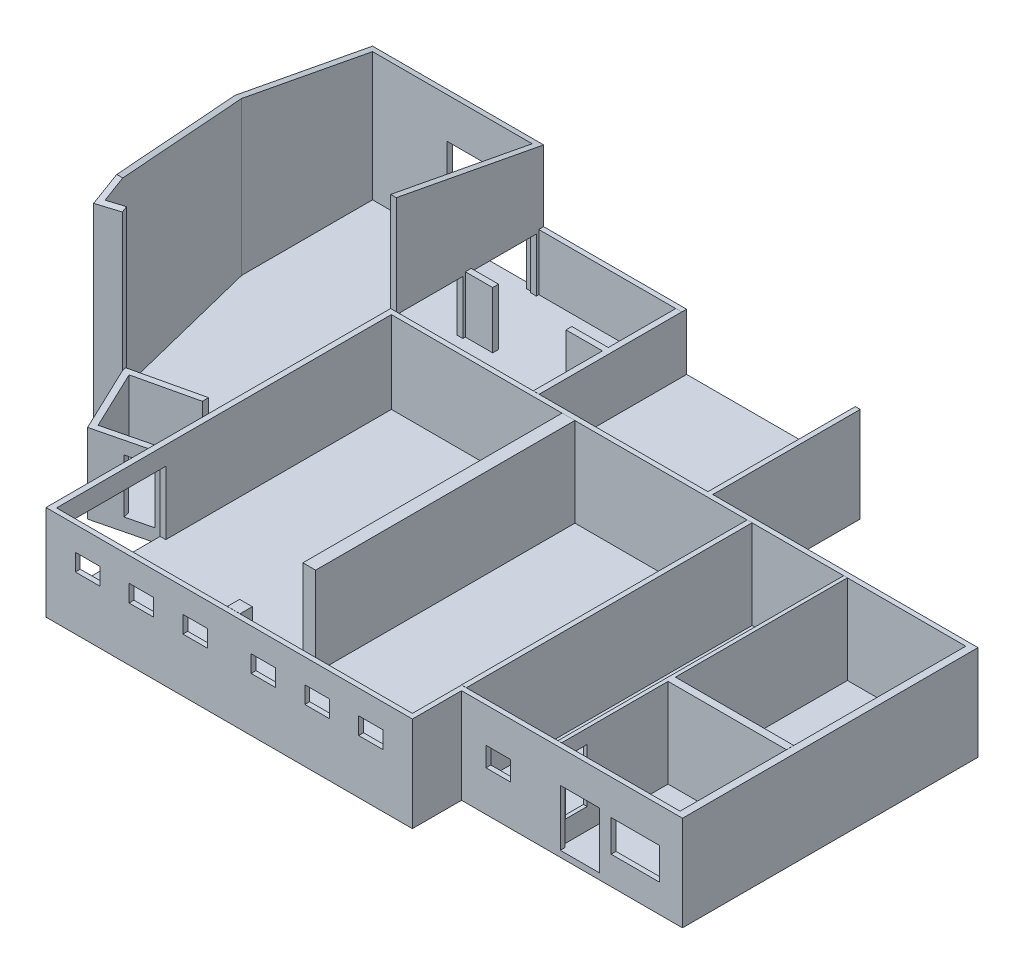
from build123d import *

# Parameters (mm, degrees)
AUFSATZ_LINEAR_AUSTRAGEN4_DEPTH      = 250
SKIZZE5_W                            = 12750
SKIZZE5_H                            = 5830
AUFSATZ_LINEAR_AUSTRAGEN5_DEPTH      = 3635
SKIZZE6_W                            = 200
SKIZZE6_H                            = 11690
SKIZZE6_W_2                          = 520
SKIZZE6_H_2                          = 10610
SKIZZE6_H_3                          = 500
SKIZZE6_W_3                          = 1120
SKIZZE6_H_4                          = 240
AUFSATZ_LINEAR_AUSTRAGEN6_DEPTH      = 3640
SCHNITT_LINEAR_AUSTRAGEN1_REACH      = 30348.456
SKIZZE7_W                            = 1980
SKIZZE7_H                            = 1300
SKIZZE7_W_2                          = 1600
SKIZZE7_H_2                          = 2300
SKIZZE7_W_3                          = 1000
SKIZZE7_H_3                          = 800
SCHNITT_LINEAR_AUSTRAGEN2_REACH      = 27879.968
SKIZZE8_W                            = 890
SKIZZE8_H                            = 2200
SCHNITT_LINEAR_AUSTRAGEN3_REACH      = 31589.813
SKIZZE9_W                            = 3870
SKIZZE9_H                            = 2600
SKIZZE9_W_2                          = 2565
SKIZZE9_H_2                          = 2200
AUFSATZ_LINEAR_AUSTRAGEN7_DEPTH      = 3000
SKIZZE11_W                           = 6990
SKIZZE11_H                           = 13700
AUFSATZ_LINEAR_AUSTRAGEN8_DEPTH      = 275
SKIZZE12_W                           = 12750
SKIZZE12_H                           = 5830
AUFSATZ_LINEAR_AUSTRAGEN9_DEPTH      = 1325
AUFSATZ_LINEAR_AUSTRAGEN10_REACH     = 31462.736
SCHNITT_LINEAR_AUSTRAGEN4_DEPTH      = 3090
AUFSATZ_LINEAR_AUSTRAGEN12_DEPTH     = 8000
AUFSATZ_LINEAR_AUSTRAGEN13_DEPTH     = 1575
SCHNITT_LINEAR_AUSTRAGEN8_DEPTH      = 37827.06409607
SCHNITT_LINEAR_AUSTRAGEN8_DEPTH_BACK = 37827.06409607
AUFSATZ_LINEAR_AUSTRAGEN14_REACH     = 31776.265
SKIZZE21_W                           = 230
SKIZZE21_H                           = 6030
SCHNITT_LINEAR_AUSTRAGEN9_DEPTH      = 1200
SCHNITT_LINEAR_AUSTRAGEN10_DEPTH     = 1050
SKIZZE24_W                           = 1040
SKIZZE24_H                           = 2200
SCHNITT_LINEAR_AUSTRAGEN11_DEPTH     = 300
SCHNITT_LINEAR_AUSTRAGEN12_REACH     = 32636.812
SKIZZE25_W                           = 1000
SKIZZE25_H                           = 700
SCHNITT_LINEAR_AUSTRAGEN13_REACH     = 32513.828
SKIZZE26_W                           = 6900
SKIZZE26_H                           = 3817.744695197
SCHNITT_LINEAR_AUSTRAGEN14_REACH     = 32489.323
SKIZZE27_W                           = 3250
SKIZZE27_H                           = 3600


with BuildPart() as part:
    # Skizze1 → Aufsatz-Linear austragen4 (new body)
    with BuildSketch(Plane(origin=(0, 0, 0), x_dir=(1, 0, 0), z_dir=(0, 1, 0))):
        Polygon((14990, -18120), (14990, -20130), (0, -20130), (0, 0), (13180, 0), (13180, -6030), (24030, -6030), (24030, -18120), align=None)
    extrude(amount=AUFSATZ_LINEAR_AUSTRAGEN4_DEPTH)

    # Skizze5 → Aufsatz-Linear austragen5 (add)
    with BuildSketch(Plane(origin=(0, 250, 0), x_dir=(1, 0, 0), z_dir=(0, 1, 0))):
        Polygon((0, -20130), (14990, -20130), (14990, -18120), (24030, -18120), (24030, -6030), (13180, -6030), (13180, 0), (0, 0), align=None)
        Polygon((23730, -6230), (23730, -17920), (14790, -17920), (14790, -19930), (230, -19930), (230, -6230), align=None, mode=Mode.SUBTRACT)
        with Locations((6605, -3115)):
            Rectangle(SKIZZE5_W, SKIZZE5_H, mode=Mode.SUBTRACT)
    extrude(amount=AUFSATZ_LINEAR_AUSTRAGEN5_DEPTH)

    # Skizze6 → Aufsatz-Linear austragen6 (add)
    with BuildSketch(Plane(origin=(0, 250, 0), x_dir=(1, 0, 0), z_dir=(0, 1, 0))):
        Polygon((18890, -17920), (18890, -13570), (23730, -13570), (23730, -13270), (18890, -13270), (18890, -6230), (18740, -6230), (18740, -17920), align=None)
        with Locations((14890, -12075)):
            Rectangle(SKIZZE6_W, SKIZZE6_H)
        Polygon((5840, -200), (6080, -200), (6080, -6030), (5840, -6030), (5840, -3205), (4350, -3205), (4350, -2965), (5840, -2965), align=None)
        with Locations((7480, -11535)):
            Rectangle(SKIZZE6_W_2, SKIZZE6_H_2)
        with Locations((7480, -19680)):
            Rectangle(SKIZZE6_W_2, SKIZZE6_H_3)
        with Locations((790, -3085)):
            Rectangle(SKIZZE6_W_3, SKIZZE6_H_4)
    extrude(amount=AUFSATZ_LINEAR_AUSTRAGEN6_DEPTH)

    # Skizze7 → Schnitt-Linear austragen1 (cut, up to next)
    with BuildSketch(Plane.XY.offset(18120), mode=Mode.PRIVATE) as schnitt_linear_austragen1_sk1:
        with Locations((22100, 1800)):
            Rectangle(SKIZZE7_W, SKIZZE7_H)
    schnitt_linear_austragen1_tool1 = extrude(schnitt_linear_austragen1_sk1.sketch, amount=-SCHNITT_LINEAR_AUSTRAGEN1_REACH, mode=Mode.PRIVATE) & part.part
    # Skizze7 → Schnitt-Linear austragen1 (cut, up to next)
    with BuildSketch(Plane.XY.offset(18120), mode=Mode.PRIVATE) as schnitt_linear_austragen1_sk2:
        with Locations((19830, 1400)):
            Rectangle(SKIZZE7_W_2, SKIZZE7_H_2)
    schnitt_linear_austragen1_tool2 = extrude(schnitt_linear_austragen1_sk2.sketch, amount=-SCHNITT_LINEAR_AUSTRAGEN1_REACH, mode=Mode.PRIVATE) & part.part
    # Skizze7 → Schnitt-Linear austragen1 (cut, up to next)
    with BuildSketch(Plane.XY.offset(18120), mode=Mode.PRIVATE) as schnitt_linear_austragen1_sk3:
        with Locations((16490, 2050)):
            Rectangle(SKIZZE7_W_3, SKIZZE7_H_3)
    schnitt_linear_austragen1_tool3 = extrude(schnitt_linear_austragen1_sk3.sketch, amount=-SCHNITT_LINEAR_AUSTRAGEN1_REACH, mode=Mode.PRIVATE) & part.part
    add(schnitt_linear_austragen1_tool1.solids().sort_by_distance((22100, 1800, 18120))[0], mode=Mode.SUBTRACT)
    add(schnitt_linear_austragen1_tool2.solids().sort_by_distance((19830, 1400, 18120))[0], mode=Mode.SUBTRACT)
    add(schnitt_linear_austragen1_tool3.solids().sort_by_distance((16490, 2050, 18120))[0], mode=Mode.SUBTRACT)

    # Skizze8 → Schnitt-Linear austragen2 (cut, up to next)
    with BuildSketch(Plane(origin=(18890, 0, 0), x_dir=(0, 0, -1), z_dir=(1, 0, 0)), mode=Mode.PRIVATE) as schnitt_linear_austragen2_sk1:
        with Locations((-17325, 2210)):
            Rectangle(SKIZZE8_W, SKIZZE8_H)
    schnitt_linear_austragen2_tool1 = extrude(schnitt_linear_austragen2_sk1.sketch, amount=-SCHNITT_LINEAR_AUSTRAGEN2_REACH, mode=Mode.PRIVATE) & part.part
    add(schnitt_linear_austragen2_tool1.solids().sort_by_distance((18890, 2210, 17325))[0], mode=Mode.SUBTRACT)

    # Skizze9 → Schnitt-Linear austragen3 (cut, up to next)
    with BuildSketch(Plane.ZY, mode=Mode.PRIVATE) as schnitt_linear_austragen3_sk1:
        with Locations((17395, 1825)):
            Rectangle(SKIZZE9_W, SKIZZE9_H)
    schnitt_linear_austragen3_tool1 = extrude(schnitt_linear_austragen3_sk1.sketch, amount=-SCHNITT_LINEAR_AUSTRAGEN3_REACH, mode=Mode.PRIVATE) & part.part
    # Skizze9 → Schnitt-Linear austragen3 (cut, up to next)
    with BuildSketch(Plane.ZY, mode=Mode.PRIVATE) as schnitt_linear_austragen3_sk2:
        with Locations((1582.5, 2675)):
            Rectangle(SKIZZE9_W_2, SKIZZE9_H_2)
    schnitt_linear_austragen3_tool2 = extrude(schnitt_linear_austragen3_sk2.sketch, amount=-SCHNITT_LINEAR_AUSTRAGEN3_REACH, mode=Mode.PRIVATE) & part.part
    # Skizze9 → Schnitt-Linear austragen3 (cut, up to next)
    with BuildSketch(Plane.ZY, mode=Mode.PRIVATE) as schnitt_linear_austragen3_sk3:
        with Locations((4587.5, 2675)):
            Rectangle(SKIZZE9_W_2, SKIZZE9_H_2)
    schnitt_linear_austragen3_tool3 = extrude(schnitt_linear_austragen3_sk3.sketch, amount=-SCHNITT_LINEAR_AUSTRAGEN3_REACH, mode=Mode.PRIVATE) & part.part
    add(schnitt_linear_austragen3_tool1.solids().sort_by_distance((0, 1825, 17395))[0], mode=Mode.SUBTRACT)
    add(schnitt_linear_austragen3_tool2.solids().sort_by_distance((0, 2675, 1582.5))[0], mode=Mode.SUBTRACT)
    add(schnitt_linear_austragen3_tool3.solids().sort_by_distance((0, 2675, 4587.5))[0], mode=Mode.SUBTRACT)

    # Skizze10 → Aufsatz-Linear austragen7 (add)
    with BuildSketch(Plane(origin=(0, 250, 0), x_dir=(1, 0, 0), z_dir=(0, 1, 0))):
        Polygon((0, -14902.502697154), (0, -15160), (-2621.386680711, -15806.785799313), (-3994.91726562, -12922.29932281), (0, -12000), (0, -12256.576026948), (-3635.371342731, -13095.867632914), (-2483.325679823, -15515.224123031), align=None)
    extrude(amount=AUFSATZ_LINEAR_AUSTRAGEN7_DEPTH)

    # Skizze11 → Aufsatz-Linear austragen8 (add)
    with BuildSketch(Plane(origin=(0, 250, 0), x_dir=(1, 0, 0), z_dir=(0, 1, 0))):
        with Locations((3725, -13080)):
            Rectangle(SKIZZE11_W, SKIZZE11_H)
    extrude(amount=AUFSATZ_LINEAR_AUSTRAGEN8_DEPTH)

    # Skizze12 → Aufsatz-Linear austragen9 (add)
    with BuildSketch(Plane(origin=(0, 250, 0), x_dir=(1, 0, 0), z_dir=(0, 1, 0))):
        with Locations((6605, -3115)):
            Rectangle(SKIZZE12_W, SKIZZE12_H)
    extrude(amount=AUFSATZ_LINEAR_AUSTRAGEN9_DEPTH)

    # Aufsatz-Linear austragen10: up to this face of the body (flat: up to its plane)
    aufsatz_linear_austragen10_end = Plane(part.part.faces().sort_by_distance((7480, 2070, 16840))[0])
    # Skizze13 → Aufsatz-Linear austragen10 (add, up to the picked face)
    with BuildSketch(Plane(origin=(0, 0, 19930), x_dir=(-1, 0, 0), z_dir=(0, 0, -1)), mode=Mode.PRIVATE) as aufsatz_linear_austragen10_sk1:
        Polygon((-4895, 525), (-10130, 250), (-4895, 250), align=None)
    aufsatz_linear_austragen10_tool1 = split(extrude(aufsatz_linear_austragen10_sk1.sketch, amount=AUFSATZ_LINEAR_AUSTRAGEN10_REACH, mode=Mode.PRIVATE), bisect_by=aufsatz_linear_austragen10_end, keep=Keep.BOTH, mode=Mode.PRIVATE)
    add(aufsatz_linear_austragen10_tool1.solids().sort_by(Axis((6640, 341.666667, 19930), (0, 0, -1)))[0])

    # Skizze14 → Schnitt-Linear austragen4 (cut)
    with BuildSketch(Plane(origin=(0, 0, 19930), x_dir=(-1, 0, 0), z_dir=(0, 0, -1))):
        Polygon((-4895, 525), (-7220, 525), (-7220, 402.865329513), align=None)
    extrude(amount=SCHNITT_LINEAR_AUSTRAGEN4_DEPTH, mode=Mode.SUBTRACT)

    # Skizze18 → Aufsatz-Linear austragen12 (add)
    with BuildSketch(Plane(origin=(0, 1575, 0), x_dir=(1, 0, 0), z_dir=(0, 1, 0))):
        Polygon((0, 0), (-6770, 0), (-6770, -5625), (-4848.656305147, -13331.088658084), (-3911.521546198, -13097.43472024), (-3969.582801141, -12864.563745934), (-4673.846585785, -13040.156428834), (-6530, -5595.531705383), (-6530, -240), (0, -240), align=None)
    extrude(amount=AUFSATZ_LINEAR_AUSTRAGEN12_DEPTH)

    # Skizze19 → Aufsatz-Linear austragen13 (add)
    with BuildSketch(Plane.XZ.offset(-1575)):
        Polygon((-2621.386680711, 15806.785799313), (0, 15160), (0, 0), (-6770, 0), (-6770, 5625), (-4848.656305147, 13331.088658084), (-3911.521546198, 13097.43472024), align=None)
    extrude(amount=AUFSATZ_LINEAR_AUSTRAGEN13_DEPTH)

    # Skizze20 → Schnitt-Linear austragen8 (cut, two sides)
    with BuildSketch(Plane.ZY.offset(-23790)) as schnitt_linear_austragen8_sk:
        Polygon((12075.002540109, 9075.964650046), (-1187.358000417, 6556.146433623), (-1198.809144532, 13266.908889698), (21923.923844096, 13266.908889698), (21923.923844096, 7205.71067909), align=None)
    extrude(amount=SCHNITT_LINEAR_AUSTRAGEN8_DEPTH, mode=Mode.SUBTRACT)
    extrude(schnitt_linear_austragen8_sk.sketch, amount=-SCHNITT_LINEAR_AUSTRAGEN8_DEPTH_BACK, mode=Mode.SUBTRACT)

    # Aufsatz-Linear austragen14: up to this plane
    aufsatz_linear_austragen14_end = Plane(origin=(24030, 9075.964650046, 12075.002540109), z_dir=(0, -0.982424863110441, 0.18665848049963168))
    # Skizze21 → Aufsatz-Linear austragen14 (add, up to the surface)
    with BuildSketch(Plane(origin=(0, 3885, 0), x_dir=(1, 0, 0), z_dir=(0, 1, 0)), mode=Mode.PRIVATE) as aufsatz_linear_austragen14_sk1:
        with Locations((115, -3015)):
            Rectangle(SKIZZE21_W, SKIZZE21_H)
    aufsatz_linear_austragen14_tool1 = split(extrude(aufsatz_linear_austragen14_sk1.sketch, amount=AUFSATZ_LINEAR_AUSTRAGEN14_REACH, mode=Mode.PRIVATE), bisect_by=aufsatz_linear_austragen14_end, keep=Keep.BOTH, mode=Mode.PRIVATE)
    add(aufsatz_linear_austragen14_tool1.solids().sort_by_distance((115, 3885, 3015))[0])

    # Skizze22 → Schnitt-Linear austragen9 (cut)
    with BuildSketch(Plane.ZY.offset(1200)):
        Polygon((9555.409574458, 1575), (9815.409574458, 1575), (9815.409574458, 1395), (10075.409574458, 1395), (10075.409574458, 1215), (10335.409574458, 1215), (10335.409574458, 1035), (10595.409574458, 1035), (10595.409574458, 855), (10855.409574458, 855), (10855.409574458, 675), (13323.160508591, 675), (13323.160508591, 5461.397070598), (9555.409574458, 5461.397070598), align=None)
    extrude(amount=-SCHNITT_LINEAR_AUSTRAGEN9_DEPTH, mode=Mode.SUBTRACT)

    # Skizze23 → Schnitt-Linear austragen10 (cut)
    with BuildSketch(Plane(origin=(0, 1575, 0), x_dir=(1, 0, 0), z_dir=(0, 1, 0))):
        Polygon((-1200, -13323.160508591), (-1200, -12533.617856299), (-3635.371342731, -13095.867632914), (-2483.325679823, -15515.224123031), (0, -14902.502697154), (0, -13323.160508591), align=None)
    extrude(amount=-SCHNITT_LINEAR_AUSTRAGEN10_DEPTH, mode=Mode.SUBTRACT)

    # Skizze24 → Schnitt-Linear austragen11 (cut)
    with BuildSketch(Plane(origin=(3525.845171827, 0, 14290.0533399), x_dir=(0.9708839558187317, 0, -0.23955029604191938), z_dir=(0.23955029604191938, 0, 0.9708839558187317))):
        with Locations((-4581.582487995, 1625)):
            Rectangle(SKIZZE24_W, SKIZZE24_H)
    extrude(amount=-SCHNITT_LINEAR_AUSTRAGEN11_DEPTH, mode=Mode.SUBTRACT)

    # Skizze25 → Schnitt-Linear austragen12 (cut, up to next)
    with BuildSketch(Plane.XY.offset(20130), mode=Mode.PRIVATE) as schnitt_linear_austragen12_sk1:
        with Locations((1700, 2550)):
            Rectangle(SKIZZE25_W, SKIZZE25_H)
    schnitt_linear_austragen12_tool1 = extrude(schnitt_linear_austragen12_sk1.sketch, amount=-SCHNITT_LINEAR_AUSTRAGEN12_REACH, mode=Mode.PRIVATE) & part.part
    # Skizze25 → Schnitt-Linear austragen12 (cut, up to next)
    with BuildSketch(Plane.XY.offset(20130), mode=Mode.PRIVATE) as schnitt_linear_austragen12_sk2:
        with Locations((3900, 2550)):
            Rectangle(SKIZZE25_W, SKIZZE25_H)
    schnitt_linear_austragen12_tool2 = extrude(schnitt_linear_austragen12_sk2.sketch, amount=-SCHNITT_LINEAR_AUSTRAGEN12_REACH, mode=Mode.PRIVATE) & part.part
    # Skizze25 → Schnitt-Linear austragen12 (cut, up to next)
    with BuildSketch(Plane.XY.offset(20130), mode=Mode.PRIVATE) as schnitt_linear_austragen12_sk3:
        with Locations((6100, 2550)):
            Rectangle(SKIZZE25_W, SKIZZE25_H)
    schnitt_linear_austragen12_tool3 = extrude(schnitt_linear_austragen12_sk3.sketch, amount=-SCHNITT_LINEAR_AUSTRAGEN12_REACH, mode=Mode.PRIVATE) & part.part
    # Skizze25 → Schnitt-Linear austragen12 (cut, up to next)
    with BuildSketch(Plane.XY.offset(20130), mode=Mode.PRIVATE) as schnitt_linear_austragen12_sk4:
        with Locations((8890, 2550)):
            Rectangle(SKIZZE25_W, SKIZZE25_H)
    schnitt_linear_austragen12_tool4 = extrude(schnitt_linear_austragen12_sk4.sketch, amount=-SCHNITT_LINEAR_AUSTRAGEN12_REACH, mode=Mode.PRIVATE) & part.part
    # Skizze25 → Schnitt-Linear austragen12 (cut, up to next)
    with BuildSketch(Plane.XY.offset(20130), mode=Mode.PRIVATE) as schnitt_linear_austragen12_sk5:
        with Locations((11090, 2550)):
            Rectangle(SKIZZE25_W, SKIZZE25_H)
    schnitt_linear_austragen12_tool5 = extrude(schnitt_linear_austragen12_sk5.sketch, amount=-SCHNITT_LINEAR_AUSTRAGEN12_REACH, mode=Mode.PRIVATE) & part.part
    # Skizze25 → Schnitt-Linear austragen12 (cut, up to next)
    with BuildSketch(Plane.XY.offset(20130), mode=Mode.PRIVATE) as schnitt_linear_austragen12_sk6:
        with Locations((13290, 2550)):
            Rectangle(SKIZZE25_W, SKIZZE25_H)
    schnitt_linear_austragen12_tool6 = extrude(schnitt_linear_austragen12_sk6.sketch, amount=-SCHNITT_LINEAR_AUSTRAGEN12_REACH, mode=Mode.PRIVATE) & part.part
    add(schnitt_linear_austragen12_tool1.solids().sort_by_distance((1700, 2550, 20130))[0], mode=Mode.SUBTRACT)
    add(schnitt_linear_austragen12_tool2.solids().sort_by_distance((3900, 2550, 20130))[0], mode=Mode.SUBTRACT)
    add(schnitt_linear_austragen12_tool3.solids().sort_by_distance((6100, 2550, 20130))[0], mode=Mode.SUBTRACT)
    add(schnitt_linear_austragen12_tool4.solids().sort_by_distance((8890, 2550, 20130))[0], mode=Mode.SUBTRACT)
    add(schnitt_linear_austragen12_tool5.solids().sort_by_distance((11090, 2550, 20130))[0], mode=Mode.SUBTRACT)
    add(schnitt_linear_austragen12_tool6.solids().sort_by_distance((13290, 2550, 20130))[0], mode=Mode.SUBTRACT)

    # Skizze26 → Schnitt-Linear austragen13 (cut, up to next)
    with BuildSketch(Plane.XY.offset(200), mode=Mode.PRIVATE) as schnitt_linear_austragen13_sk1:
        with Locations((9530, 3483.872347599)):
            Rectangle(SKIZZE26_W, SKIZZE26_H)
    schnitt_linear_austragen13_tool1 = extrude(schnitt_linear_austragen13_sk1.sketch, amount=-SCHNITT_LINEAR_AUSTRAGEN13_REACH, mode=Mode.PRIVATE) & part.part
    add(schnitt_linear_austragen13_tool1.solids().sort_by_distance((9530, 3483.872348, 200))[0], mode=Mode.SUBTRACT)

    # Skizze27 → Schnitt-Linear austragen14 (cut, up to next)
    with BuildSketch(Plane.XY.offset(240), mode=Mode.PRIVATE) as schnitt_linear_austragen14_sk1:
        with Locations((-1865, 3375)):
            Rectangle(SKIZZE27_W, SKIZZE27_H)
    schnitt_linear_austragen14_tool1 = extrude(schnitt_linear_austragen14_sk1.sketch, amount=-SCHNITT_LINEAR_AUSTRAGEN14_REACH, mode=Mode.PRIVATE) & part.part
    add(schnitt_linear_austragen14_tool1.solids().sort_by_distance((-1865, 3375, 240))[0], mode=Mode.SUBTRACT)


solid = part.part
